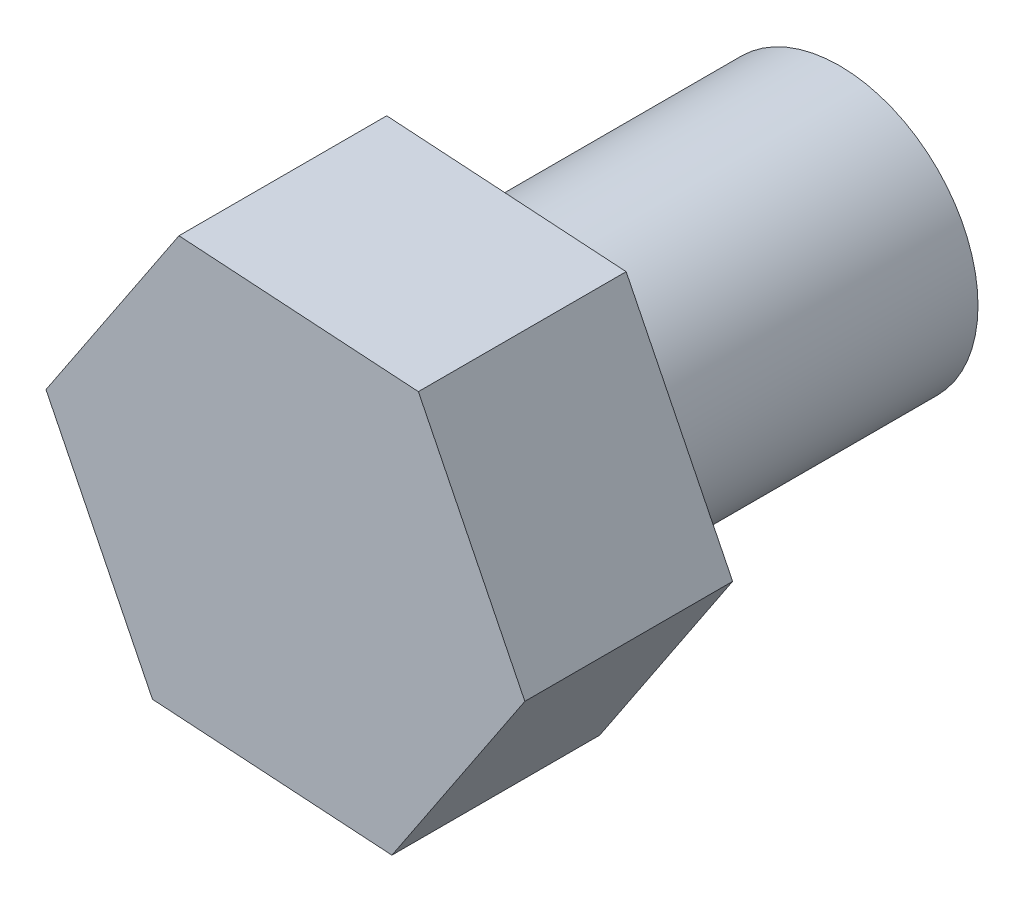
from build123d import *

# Parameters (mm, degrees)
EXTRUDE_1_DEPTH = 3
SKETCH_2_R      = 2
EXTRUDE_2_DEPTH = 5


with BuildPart() as part:
    # 草图1 → 凸台-拉伸1 (new body)
    with BuildSketch(Plane.XY):
        Polygon((1.537378268, -3.104266107), (3.457062442, -0.220724418), (1.919684175, 2.883541688), (-1.537378268, 3.104266107), (-3.457062442, 0.220724418), (-1.919684175, -2.883541688), align=None)
    extrude(amount=EXTRUDE_1_DEPTH)

    # 草图2 → 凸台-拉伸2 (add)
    with BuildSketch(Plane(origin=(0, 0, 0), x_dir=(-1, 0, 0), z_dir=(0, 0, -1))):
        Circle(SKETCH_2_R)
    extrude(amount=EXTRUDE_2_DEPTH)


solid = part.part
